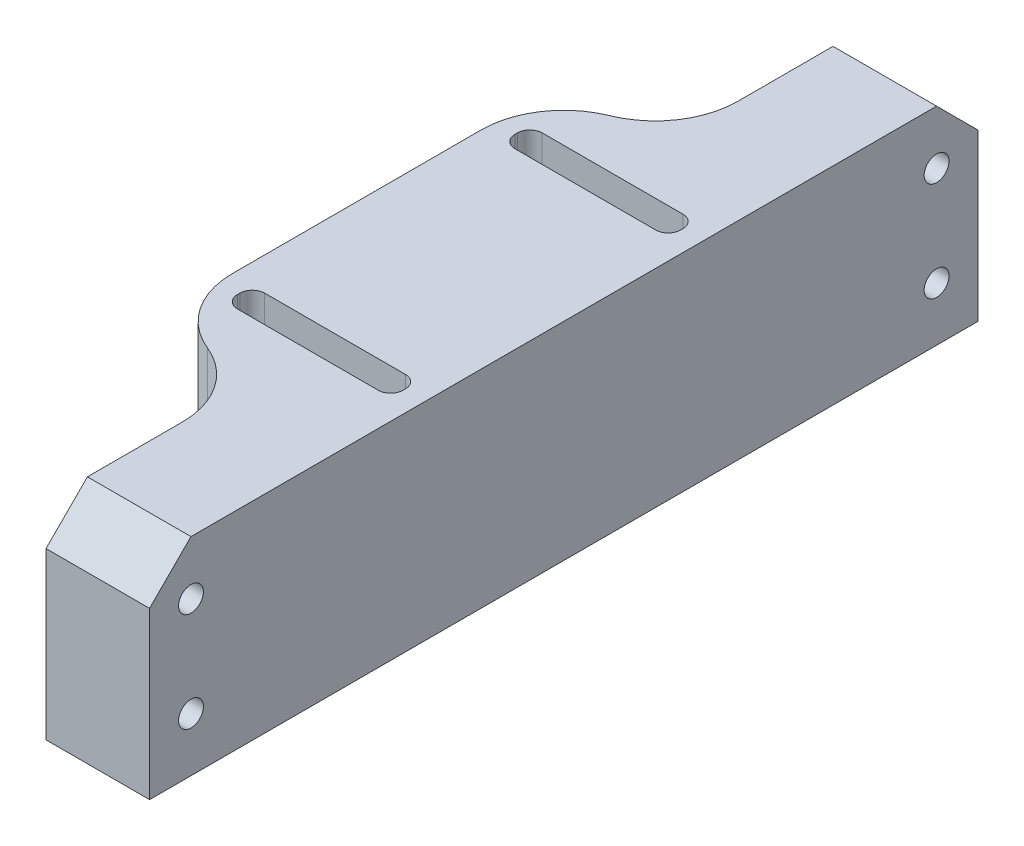
from build123d import *

# Parameters (mm, degrees)
SKETCH_1_W          = 20
SKETCH_1_H          = 3.3
EXTRUDE_1_DEPTH     = 25
SKETCH_2_R          = 1.5
CUT_EXTRUDE_1_DEPTH = 13.5
SKETCH_3_R          = 1.5
CUT_EXTRUDE_2_DEPTH = 13.5
FILLET_6_R          = 10
FILLET_7_R          = 1.5
CHAMFER_1_SIZE      = 5
FILLET_8_R          = 10


with BuildPart() as part:
    # Эскиз1 → Бобышка-Вытянуть1 (new body)
    with BuildSketch(Plane(origin=(0, 0, 0), x_dir=(1, 0, 0), z_dir=(0, 1, 0))):
        Polygon((-12.5, -25), (0, -25), (0, -50), (12.5, -50), (12.5, 50), (0, 50), (0, 25), (-12.5, 25), align=None)
        with Locations((0, 16.75)):
            Rectangle(SKETCH_1_W, SKETCH_1_H, mode=Mode.SUBTRACT)
        with Locations((0, -16.75)):
            Rectangle(SKETCH_1_W, SKETCH_1_H, mode=Mode.SUBTRACT)
    extrude(amount=EXTRUDE_1_DEPTH)

    # Эскиз2 → Вырез-Вытянуть1 (cut, through all)
    with BuildSketch(Plane.ZY):
        with Locations((-45, 6.5)):
            Circle(SKETCH_2_R)
        with Locations((-45, 18.5)):
            Circle(SKETCH_2_R)
    extrude(amount=-CUT_EXTRUDE_1_DEPTH, mode=Mode.SUBTRACT)

    # Эскиз3 → Вырез-Вытянуть2 (cut, through all)
    with BuildSketch(Plane.ZY):
        with Locations((45, 6.5)):
            Circle(SKETCH_3_R)
        with Locations((45, 18.5)):
            Circle(SKETCH_3_R)
    extrude(amount=-CUT_EXTRUDE_2_DEPTH, mode=Mode.SUBTRACT)

    # Скругление6
    fillet_6_edges = [part.edges().sort_by_distance(p)[0] for p in [
        (-12.5, 12.5, 25),
        (-12.5, 12.5, -25),
    ]]
    fillet(fillet_6_edges, radius=FILLET_6_R)

    # Скругление7
    fillet_7_edges = [part.edges().sort_by_distance(p)[0] for p in [
        (-10, 12.5, -18.4),
        (-10, 12.5, -15.1),
        (10, 12.5, -15.1),
        (10, 12.5, -18.4),
        (-10, 12.5, 15.1),
        (-10, 12.5, 18.4),
        (10, 12.5, 18.4),
        (10, 12.5, 15.1),
    ]]
    fillet(fillet_7_edges, radius=FILLET_7_R)

    # Фаска1
    chamfer_1_edges = [part.edges().sort_by_distance(p)[0] for p in [
        (6.25, 25, 50),
        (6.25, 25, -50),
    ]]
    chamfer(chamfer_1_edges, length=CHAMFER_1_SIZE)

    # Скругление8
    fillet_8_edges = [part.edges().sort_by_distance(p)[0] for p in [
        (0, 12.5, 25),
        (0, 12.5, -25),
    ]]
    fillet(fillet_8_edges, radius=FILLET_8_R)


solid = part.part
